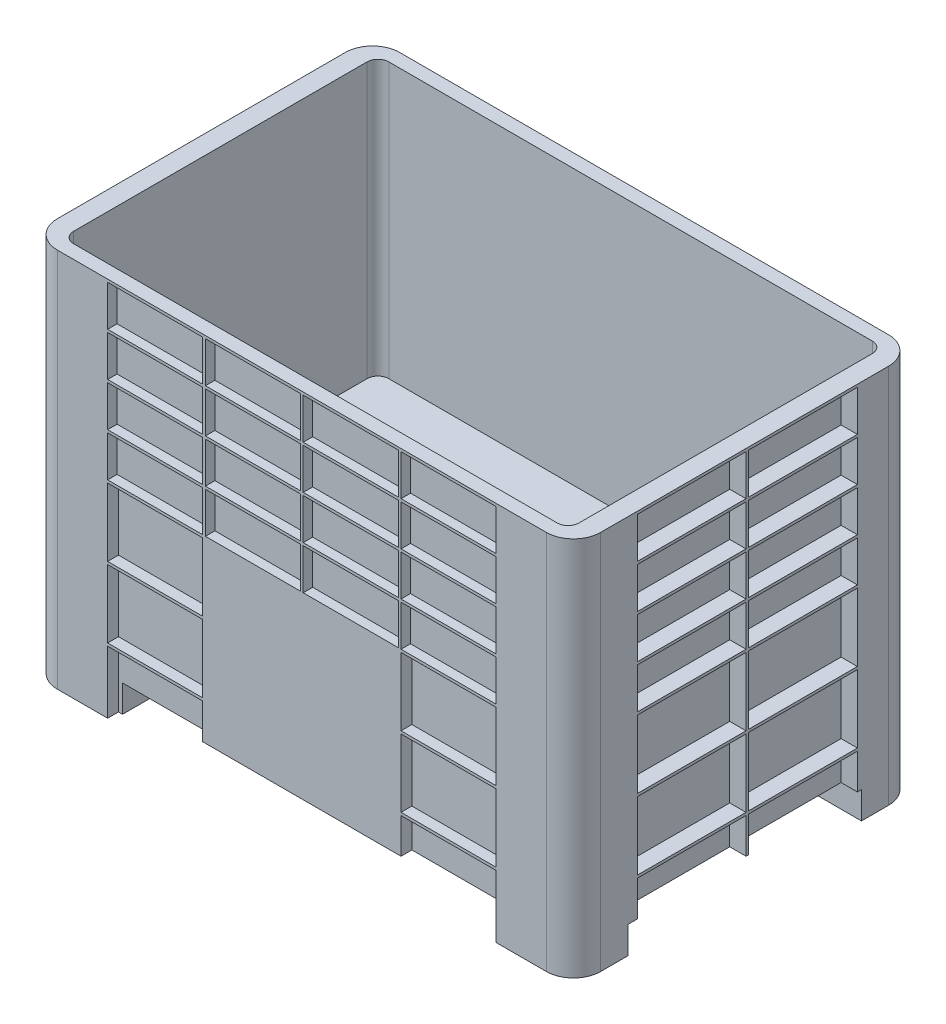
from build123d import *

# Parameters (mm, degrees)
AUFSATZ_LINEAR_AUSTRAGEN1_DEPTH = 650
AUFSATZ_LINEAR_AUSTRAGEN2_DEPTH = 50
SPIEGELN2_COPY_1_DEPTH          = 50
SCHNITT_LINEAR_AUSTRAGEN1_DEPTH = 505
SKIZZE4_W                       = 175
SKIZZE4_H                       = 75
SCHNITT_LINEAR_AUSTRAGEN2_DEPTH = 17.42216744
LINEARES_MUSTER1_COUNT          = 4
LINEARES_MUSTER1_PITCH          = 180
LINEARES_MUSTER1_COUNT_DIR2     = 4
LINEARES_MUSTER1_PITCH_DIR2     = 80
SKIZZE5_W                       = 175
SKIZZE5_H                       = 125
SCHNITT_LINEAR_AUSTRAGEN3_DEPTH = 20
LINEARES_MUSTER2_COUNT          = 2
LINEARES_MUSTER2_PITCH          = 540
LINEARES_MUSTER2_COUNT_DIR2     = 3
LINEARES_MUSTER2_PITCH_DIR2     = 130
SPIEGELN3_COPY_1_SKETCH_W       = 175
SPIEGELN3_COPY_1_SKETCH_H       = 75
SPIEGELN3_COPY_1_DEPTH          = 17.42216744
SPIEGELN3_COPY_2_SKETCH_W       = 175
SPIEGELN3_COPY_2_SKETCH_H       = 75
SPIEGELN3_COPY_2_DEPTH          = 17.42216744
SPIEGELN3_COPY_3_SKETCH_W       = 175
SPIEGELN3_COPY_3_SKETCH_H       = 75
SPIEGELN3_COPY_3_DEPTH          = 17.42216744
SPIEGELN3_COPY_4_SKETCH_W       = 175
SPIEGELN3_COPY_4_SKETCH_H       = 75
SPIEGELN3_COPY_4_DEPTH          = 17.42216744
SPIEGELN3_COPY_5_SKETCH_W       = 175
SPIEGELN3_COPY_5_SKETCH_H       = 75
SPIEGELN3_COPY_5_DEPTH          = 17.42216744
SPIEGELN3_COPY_6_SKETCH_W       = 175
SPIEGELN3_COPY_6_SKETCH_H       = 75
SPIEGELN3_COPY_6_DEPTH          = 17.42216744
SPIEGELN3_COPY_7_SKETCH_W       = 175
SPIEGELN3_COPY_7_SKETCH_H       = 75
SPIEGELN3_COPY_7_DEPTH          = 17.42216744
SPIEGELN3_COPY_8_SKETCH_W       = 175
SPIEGELN3_COPY_8_SKETCH_H       = 75
SPIEGELN3_COPY_8_DEPTH          = 17.42216744
SPIEGELN3_COPY_9_SKETCH_W       = 175
SPIEGELN3_COPY_9_SKETCH_H       = 75
SPIEGELN3_COPY_9_DEPTH          = 17.42216744
SPIEGELN3_COPY_10_SKETCH_W      = 175
SPIEGELN3_COPY_10_SKETCH_H      = 75
SPIEGELN3_COPY_10_DEPTH         = 17.42216744
SPIEGELN3_COPY_11_SKETCH_W      = 175
SPIEGELN3_COPY_11_SKETCH_H      = 75
SPIEGELN3_COPY_11_DEPTH         = 17.42216744
SPIEGELN3_COPY_12_SKETCH_W      = 175
SPIEGELN3_COPY_12_SKETCH_H      = 75
SPIEGELN3_COPY_12_DEPTH         = 17.42216744
SPIEGELN3_COPY_13_SKETCH_W      = 175
SPIEGELN3_COPY_13_SKETCH_H      = 75
SPIEGELN3_COPY_13_DEPTH         = 17.42216744
SPIEGELN3_COPY_14_SKETCH_W      = 175
SPIEGELN3_COPY_14_SKETCH_H      = 75
SPIEGELN3_COPY_14_DEPTH         = 17.42216744
SPIEGELN3_COPY_15_SKETCH_W      = 175
SPIEGELN3_COPY_15_SKETCH_H      = 75
SPIEGELN3_COPY_15_DEPTH         = 17.42216744
SPIEGELN3_COPY_16_SKETCH_W      = 175
SPIEGELN3_COPY_16_SKETCH_H      = 125
SPIEGELN3_COPY_16_DEPTH         = 20
SPIEGELN3_COPY_17_SKETCH_W      = 175
SPIEGELN3_COPY_17_SKETCH_H      = 125
SPIEGELN3_COPY_17_DEPTH         = 20
SPIEGELN3_COPY_18_SKETCH_W      = 175
SPIEGELN3_COPY_18_SKETCH_H      = 125
SPIEGELN3_COPY_18_DEPTH         = 20
SPIEGELN3_COPY_19_SKETCH_W      = 175
SPIEGELN3_COPY_19_SKETCH_H      = 125
SPIEGELN3_COPY_19_DEPTH         = 20
SPIEGELN3_COPY_20_SKETCH_W      = 175
SPIEGELN3_COPY_20_SKETCH_H      = 125
SPIEGELN3_COPY_20_DEPTH         = 20
SKIZZE6_W                       = 200
SKIZZE6_H                       = 75
SCHNITT_LINEAR_AUSTRAGEN4_DEPTH = 30
LINEARES_MUSTER3_COUNT          = 2
LINEARES_MUSTER3_PITCH          = 205
LINEARES_MUSTER3_COUNT_DIR2     = 4
LINEARES_MUSTER3_PITCH_DIR2     = 80
SKIZZE7_W                       = 200
SKIZZE7_H                       = 125
SCHNITT_LINEAR_AUSTRAGEN5_DEPTH = 30
LINEARES_MUSTER4_COUNT          = 2
LINEARES_MUSTER4_PITCH          = 205
LINEARES_MUSTER4_COUNT_DIR2     = 3
LINEARES_MUSTER4_PITCH_DIR2     = 130
SPIEGELN4_COPY_1_SKETCH_W       = 200
SPIEGELN4_COPY_1_SKETCH_H       = 75
SPIEGELN4_COPY_1_DEPTH          = 30
SPIEGELN4_COPY_2_SKETCH_W       = 200
SPIEGELN4_COPY_2_SKETCH_H       = 75
SPIEGELN4_COPY_2_DEPTH          = 30
SPIEGELN4_COPY_3_SKETCH_W       = 200
SPIEGELN4_COPY_3_SKETCH_H       = 75
SPIEGELN4_COPY_3_DEPTH          = 30
SPIEGELN4_COPY_4_SKETCH_W       = 200
SPIEGELN4_COPY_4_SKETCH_H       = 75
SPIEGELN4_COPY_4_DEPTH          = 30
SPIEGELN4_COPY_5_SKETCH_W       = 200
SPIEGELN4_COPY_5_SKETCH_H       = 75
SPIEGELN4_COPY_5_DEPTH          = 30
SPIEGELN4_COPY_6_SKETCH_W       = 200
SPIEGELN4_COPY_6_SKETCH_H       = 75
SPIEGELN4_COPY_6_DEPTH          = 30
SPIEGELN4_COPY_7_SKETCH_W       = 200
SPIEGELN4_COPY_7_SKETCH_H       = 75
SPIEGELN4_COPY_7_DEPTH          = 30
SPIEGELN4_COPY_8_SKETCH_W       = 200
SPIEGELN4_COPY_8_SKETCH_H       = 125
SPIEGELN4_COPY_8_DEPTH          = 30
SPIEGELN4_COPY_9_SKETCH_W       = 200
SPIEGELN4_COPY_9_SKETCH_H       = 125
SPIEGELN4_COPY_9_DEPTH          = 30
SPIEGELN4_COPY_10_SKETCH_W      = 200
SPIEGELN4_COPY_10_SKETCH_H      = 125
SPIEGELN4_COPY_10_DEPTH         = 30
SPIEGELN4_COPY_11_SKETCH_W      = 200
SPIEGELN4_COPY_11_SKETCH_H      = 125
SPIEGELN4_COPY_11_DEPTH         = 30
SPIEGELN4_COPY_12_SKETCH_W      = 200
SPIEGELN4_COPY_12_SKETCH_H      = 125
SPIEGELN4_COPY_12_DEPTH         = 30


with BuildPart() as part:
    # Skizze1 → Aufsatz-Linear austragen1 (new body)
    with BuildSketch(Plane(origin=(0, 100, 0), x_dir=(1, 0, 0), z_dir=(0, 1, 0))):
        with BuildLine():
            Line((-450, -315), (450, -315))
            ThreePointArc((450, -315), (485.355339059, -300.355339059), (500, -265))
            Line((500, -265), (500, 265))
            ThreePointArc((500, 265), (485.355339059, 300.355339059), (450, 315))
            Line((450, 315), (-450, 315))
            ThreePointArc((-450, 315), (-485.355339059, 300.355339059), (-500, 265))
            Line((-500, 265), (-500, -265))
            ThreePointArc((-500, -265), (-485.355339059, -300.355339059), (-450, -315))
        make_face()
    extrude(amount=AUFSATZ_LINEAR_AUSTRAGEN1_DEPTH)

    # Skizze2 → Aufsatz-Linear austragen2 (add)
    with BuildSketch(Plane.XZ.offset(-100)):
        with BuildLine():
            Line((450, 315), (350, 315))
            Line((350, 315), (350, 215))
            Line((350, 215), (500, 215))
            Line((500, 215), (500, 265))
            ThreePointArc((500, 265), (485.355339059, 300.355339059), (450, 315))
        make_face()
    aufsatz_linear_austragen2 = extrude(amount=AUFSATZ_LINEAR_AUSTRAGEN2_DEPTH)

    # Spiegeln1: Aufsatz-Linear austragen2 across plane
    add(aufsatz_linear_austragen2.mirror(Plane.XY))

    # Spiegeln2: Aufsatz-Linear austragen2 across plane
    add(aufsatz_linear_austragen2.mirror(Plane(origin=(0, 0, 0), x_dir=(0, 0, 1), z_dir=(1, 0, 0))))

    # Spiegeln2 copy 1 sketch → Spiegeln2 copy 1 (add)
    with BuildSketch(Plane(origin=(0, 100, 0), x_dir=(-1, 0, 0), z_dir=(0, -1, 0))):
        with BuildLine():
            Line((450, 315), (350, 315))
            Line((350, 315), (350, 215))
            Line((350, 215), (500, 215))
            Line((500, 215), (500, 265))
            ThreePointArc((500, 265), (485.355339059, 300.355339059), (450, 315))
        make_face()
    extrude(amount=SPIEGELN2_COPY_1_DEPTH)

    # Skizze3 → Schnitt-Linear austragen1 (cut)
    with BuildSketch(Plane(origin=(0, 750, 0), x_dir=(1, 0, 0), z_dir=(0, 1, 0))):
        with BuildLine():
            Line((445, -290), (-445, -290))
            ThreePointArc((-445, -290), (-459.142135624, -284.142135624), (-465, -270))
            Line((-465, -270), (-465, 270))
            ThreePointArc((-465, 270), (-459.142135624, 284.142135624), (-445, 290))
            Line((-445, 290), (445, 290))
            ThreePointArc((445, 290), (459.142135624, 284.142135624), (465, 270))
            Line((465, 270), (465, -270))
            ThreePointArc((465, -270), (459.142135624, -284.142135624), (445, -290))
        make_face()
    extrude(amount=-SCHNITT_LINEAR_AUSTRAGEN1_DEPTH, mode=Mode.SUBTRACT)

    # Skizze4 → Schnitt-Linear austragen2 (cut)
    with BuildSketch(Plane.XY.offset(315)):
        with Locations((-270, 707.5)):
            Rectangle(SKIZZE4_W, SKIZZE4_H)
    schnitt_linear_austragen2 = extrude(amount=-SCHNITT_LINEAR_AUSTRAGEN2_DEPTH, mode=Mode.SUBTRACT)

    # Lineares Muster1: Schnitt-Linear austragen2 4 × 4
    with Locations(*[(i * LINEARES_MUSTER1_PITCH, -j * LINEARES_MUSTER1_PITCH_DIR2, 0) for i in range(LINEARES_MUSTER1_COUNT) for j in range(LINEARES_MUSTER1_COUNT_DIR2) if (i, j) != (0, 0)]):
        add(schnitt_linear_austragen2, mode=Mode.SUBTRACT)

    # Skizze5 → Schnitt-Linear austragen3 (cut)
    with BuildSketch(Plane.XY.offset(315)):
        with Locations((-270, 362.5)):
            Rectangle(SKIZZE5_W, SKIZZE5_H)
    schnitt_linear_austragen3 = extrude(amount=-SCHNITT_LINEAR_AUSTRAGEN3_DEPTH, mode=Mode.SUBTRACT)

    # Lineares Muster2: Schnitt-Linear austragen3 2 × 3
    with Locations(*[(i * LINEARES_MUSTER2_PITCH, -j * LINEARES_MUSTER2_PITCH_DIR2, 0) for i in range(LINEARES_MUSTER2_COUNT) for j in range(LINEARES_MUSTER2_COUNT_DIR2) if (i, j) != (0, 0)]):
        add(schnitt_linear_austragen3, mode=Mode.SUBTRACT)

    # Spiegeln3: Schnitt-Linear austragen2, Schnitt-Linear austragen3 across plane
    add(schnitt_linear_austragen2.mirror(Plane.XY), mode=Mode.SUBTRACT)
    add(schnitt_linear_austragen3.mirror(Plane.XY), mode=Mode.SUBTRACT)

    # Spiegeln3 copy 1 sketch → Spiegeln3 copy 1 (cut)
    with BuildSketch(Plane(origin=(0, -80, -315), x_dir=(1, 0, 0), z_dir=(0, 0, -1))):
        with Locations((-270, -707.5)):
            Rectangle(SPIEGELN3_COPY_1_SKETCH_W, SPIEGELN3_COPY_1_SKETCH_H)
    extrude(amount=-SPIEGELN3_COPY_1_DEPTH, mode=Mode.SUBTRACT)

    # Spiegeln3 copy 2 sketch → Spiegeln3 copy 2 (cut)
    with BuildSketch(Plane(origin=(0, -160, -315), x_dir=(1, 0, 0), z_dir=(0, 0, -1))):
        with Locations((-270, -707.5)):
            Rectangle(SPIEGELN3_COPY_2_SKETCH_W, SPIEGELN3_COPY_2_SKETCH_H)
    extrude(amount=-SPIEGELN3_COPY_2_DEPTH, mode=Mode.SUBTRACT)

    # Spiegeln3 copy 3 sketch → Spiegeln3 copy 3 (cut)
    with BuildSketch(Plane(origin=(0, -240, -315), x_dir=(1, 0, 0), z_dir=(0, 0, -1))):
        with Locations((-270, -707.5)):
            Rectangle(SPIEGELN3_COPY_3_SKETCH_W, SPIEGELN3_COPY_3_SKETCH_H)
    extrude(amount=-SPIEGELN3_COPY_3_DEPTH, mode=Mode.SUBTRACT)

    # Spiegeln3 copy 4 sketch → Spiegeln3 copy 4 (cut)
    with BuildSketch(Plane(origin=(180, 0, -315), x_dir=(1, 0, 0), z_dir=(0, 0, -1))):
        with Locations((-270, -707.5)):
            Rectangle(SPIEGELN3_COPY_4_SKETCH_W, SPIEGELN3_COPY_4_SKETCH_H)
    extrude(amount=-SPIEGELN3_COPY_4_DEPTH, mode=Mode.SUBTRACT)

    # Spiegeln3 copy 5 sketch → Spiegeln3 copy 5 (cut)
    with BuildSketch(Plane(origin=(180, -80, -315), x_dir=(1, 0, 0), z_dir=(0, 0, -1))):
        with Locations((-270, -707.5)):
            Rectangle(SPIEGELN3_COPY_5_SKETCH_W, SPIEGELN3_COPY_5_SKETCH_H)
    extrude(amount=-SPIEGELN3_COPY_5_DEPTH, mode=Mode.SUBTRACT)

    # Spiegeln3 copy 6 sketch → Spiegeln3 copy 6 (cut)
    with BuildSketch(Plane(origin=(180, -160, -315), x_dir=(1, 0, 0), z_dir=(0, 0, -1))):
        with Locations((-270, -707.5)):
            Rectangle(SPIEGELN3_COPY_6_SKETCH_W, SPIEGELN3_COPY_6_SKETCH_H)
    extrude(amount=-SPIEGELN3_COPY_6_DEPTH, mode=Mode.SUBTRACT)

    # Spiegeln3 copy 7 sketch → Spiegeln3 copy 7 (cut)
    with BuildSketch(Plane(origin=(180, -240, -315), x_dir=(1, 0, 0), z_dir=(0, 0, -1))):
        with Locations((-270, -707.5)):
            Rectangle(SPIEGELN3_COPY_7_SKETCH_W, SPIEGELN3_COPY_7_SKETCH_H)
    extrude(amount=-SPIEGELN3_COPY_7_DEPTH, mode=Mode.SUBTRACT)

    # Spiegeln3 copy 8 sketch → Spiegeln3 copy 8 (cut)
    with BuildSketch(Plane(origin=(360, 0, -315), x_dir=(1, 0, 0), z_dir=(0, 0, -1))):
        with Locations((-270, -707.5)):
            Rectangle(SPIEGELN3_COPY_8_SKETCH_W, SPIEGELN3_COPY_8_SKETCH_H)
    extrude(amount=-SPIEGELN3_COPY_8_DEPTH, mode=Mode.SUBTRACT)

    # Spiegeln3 copy 9 sketch → Spiegeln3 copy 9 (cut)
    with BuildSketch(Plane(origin=(360, -80, -315), x_dir=(1, 0, 0), z_dir=(0, 0, -1))):
        with Locations((-270, -707.5)):
            Rectangle(SPIEGELN3_COPY_9_SKETCH_W, SPIEGELN3_COPY_9_SKETCH_H)
    extrude(amount=-SPIEGELN3_COPY_9_DEPTH, mode=Mode.SUBTRACT)

    # Spiegeln3 copy 10 sketch → Spiegeln3 copy 10 (cut)
    with BuildSketch(Plane(origin=(360, -160, -315), x_dir=(1, 0, 0), z_dir=(0, 0, -1))):
        with Locations((-270, -707.5)):
            Rectangle(SPIEGELN3_COPY_10_SKETCH_W, SPIEGELN3_COPY_10_SKETCH_H)
    extrude(amount=-SPIEGELN3_COPY_10_DEPTH, mode=Mode.SUBTRACT)

    # Spiegeln3 copy 11 sketch → Spiegeln3 copy 11 (cut)
    with BuildSketch(Plane(origin=(360, -240, -315), x_dir=(1, 0, 0), z_dir=(0, 0, -1))):
        with Locations((-270, -707.5)):
            Rectangle(SPIEGELN3_COPY_11_SKETCH_W, SPIEGELN3_COPY_11_SKETCH_H)
    extrude(amount=-SPIEGELN3_COPY_11_DEPTH, mode=Mode.SUBTRACT)

    # Spiegeln3 copy 12 sketch → Spiegeln3 copy 12 (cut)
    with BuildSketch(Plane(origin=(540, 0, -315), x_dir=(1, 0, 0), z_dir=(0, 0, -1))):
        with Locations((-270, -707.5)):
            Rectangle(SPIEGELN3_COPY_12_SKETCH_W, SPIEGELN3_COPY_12_SKETCH_H)
    extrude(amount=-SPIEGELN3_COPY_12_DEPTH, mode=Mode.SUBTRACT)

    # Spiegeln3 copy 13 sketch → Spiegeln3 copy 13 (cut)
    with BuildSketch(Plane(origin=(540, -80, -315), x_dir=(1, 0, 0), z_dir=(0, 0, -1))):
        with Locations((-270, -707.5)):
            Rectangle(SPIEGELN3_COPY_13_SKETCH_W, SPIEGELN3_COPY_13_SKETCH_H)
    extrude(amount=-SPIEGELN3_COPY_13_DEPTH, mode=Mode.SUBTRACT)

    # Spiegeln3 copy 14 sketch → Spiegeln3 copy 14 (cut)
    with BuildSketch(Plane(origin=(540, -160, -315), x_dir=(1, 0, 0), z_dir=(0, 0, -1))):
        with Locations((-270, -707.5)):
            Rectangle(SPIEGELN3_COPY_14_SKETCH_W, SPIEGELN3_COPY_14_SKETCH_H)
    extrude(amount=-SPIEGELN3_COPY_14_DEPTH, mode=Mode.SUBTRACT)

    # Spiegeln3 copy 15 sketch → Spiegeln3 copy 15 (cut)
    with BuildSketch(Plane(origin=(540, -240, -315), x_dir=(1, 0, 0), z_dir=(0, 0, -1))):
        with Locations((-270, -707.5)):
            Rectangle(SPIEGELN3_COPY_15_SKETCH_W, SPIEGELN3_COPY_15_SKETCH_H)
    extrude(amount=-SPIEGELN3_COPY_15_DEPTH, mode=Mode.SUBTRACT)

    # Spiegeln3 copy 16 sketch → Spiegeln3 copy 16 (cut)
    with BuildSketch(Plane(origin=(0, -130, -315), x_dir=(1, 0, 0), z_dir=(0, 0, -1))):
        with Locations((-270, -362.5)):
            Rectangle(SPIEGELN3_COPY_16_SKETCH_W, SPIEGELN3_COPY_16_SKETCH_H)
    extrude(amount=-SPIEGELN3_COPY_16_DEPTH, mode=Mode.SUBTRACT)

    # Spiegeln3 copy 17 sketch → Spiegeln3 copy 17 (cut)
    with BuildSketch(Plane(origin=(0, -260, -315), x_dir=(1, 0, 0), z_dir=(0, 0, -1))):
        with Locations((-270, -362.5)):
            Rectangle(SPIEGELN3_COPY_17_SKETCH_W, SPIEGELN3_COPY_17_SKETCH_H)
    extrude(amount=-SPIEGELN3_COPY_17_DEPTH, mode=Mode.SUBTRACT)

    # Spiegeln3 copy 18 sketch → Spiegeln3 copy 18 (cut)
    with BuildSketch(Plane(origin=(540, 0, -315), x_dir=(1, 0, 0), z_dir=(0, 0, -1))):
        with Locations((-270, -362.5)):
            Rectangle(SPIEGELN3_COPY_18_SKETCH_W, SPIEGELN3_COPY_18_SKETCH_H)
    extrude(amount=-SPIEGELN3_COPY_18_DEPTH, mode=Mode.SUBTRACT)

    # Spiegeln3 copy 19 sketch → Spiegeln3 copy 19 (cut)
    with BuildSketch(Plane(origin=(540, -130, -315), x_dir=(1, 0, 0), z_dir=(0, 0, -1))):
        with Locations((-270, -362.5)):
            Rectangle(SPIEGELN3_COPY_19_SKETCH_W, SPIEGELN3_COPY_19_SKETCH_H)
    extrude(amount=-SPIEGELN3_COPY_19_DEPTH, mode=Mode.SUBTRACT)

    # Spiegeln3 copy 20 sketch → Spiegeln3 copy 20 (cut)
    with BuildSketch(Plane(origin=(540, -260, -315), x_dir=(1, 0, 0), z_dir=(0, 0, -1))):
        with Locations((-270, -362.5)):
            Rectangle(SPIEGELN3_COPY_20_SKETCH_W, SPIEGELN3_COPY_20_SKETCH_H)
    extrude(amount=-SPIEGELN3_COPY_20_DEPTH, mode=Mode.SUBTRACT)

    # Skizze6 → Schnitt-Linear austragen4 (cut)
    with BuildSketch(Plane.ZY.offset(500)):
        with Locations((-107.5, 707.5)):
            Rectangle(SKIZZE6_W, SKIZZE6_H)
    schnitt_linear_austragen4 = extrude(amount=-SCHNITT_LINEAR_AUSTRAGEN4_DEPTH, mode=Mode.SUBTRACT)

    # Lineares Muster3: Schnitt-Linear austragen4 2 × 4
    with Locations(*[(0, -j * LINEARES_MUSTER3_PITCH_DIR2, i * LINEARES_MUSTER3_PITCH) for i in range(LINEARES_MUSTER3_COUNT) for j in range(LINEARES_MUSTER3_COUNT_DIR2) if (i, j) != (0, 0)]):
        add(schnitt_linear_austragen4, mode=Mode.SUBTRACT)

    # Skizze7 → Schnitt-Linear austragen5 (cut)
    with BuildSketch(Plane.ZY.offset(500)):
        with Locations((-107.5, 362.5)):
            Rectangle(SKIZZE7_W, SKIZZE7_H)
    schnitt_linear_austragen5 = extrude(amount=-SCHNITT_LINEAR_AUSTRAGEN5_DEPTH, mode=Mode.SUBTRACT)

    # Lineares Muster4: Schnitt-Linear austragen5 2 × 3
    with Locations(*[(0, -j * LINEARES_MUSTER4_PITCH_DIR2, i * LINEARES_MUSTER4_PITCH) for i in range(LINEARES_MUSTER4_COUNT) for j in range(LINEARES_MUSTER4_COUNT_DIR2) if (i, j) != (0, 0)]):
        add(schnitt_linear_austragen5, mode=Mode.SUBTRACT)

    # Spiegeln4: Schnitt-Linear austragen4, Schnitt-Linear austragen5 across plane
    add(schnitt_linear_austragen4.mirror(Plane(origin=(0, 0, 0), x_dir=(0, 0, 1), z_dir=(1, 0, 0))), mode=Mode.SUBTRACT)
    add(schnitt_linear_austragen5.mirror(Plane(origin=(0, 0, 0), x_dir=(0, 0, 1), z_dir=(1, 0, 0))), mode=Mode.SUBTRACT)

    # Spiegeln4 copy 1 sketch → Spiegeln4 copy 1 (cut)
    with BuildSketch(Plane(origin=(500, -80, 0), x_dir=(0, 0, 1), z_dir=(1, 0, 0))):
        with Locations((-107.5, -707.5)):
            Rectangle(SPIEGELN4_COPY_1_SKETCH_W, SPIEGELN4_COPY_1_SKETCH_H)
    extrude(amount=-SPIEGELN4_COPY_1_DEPTH, mode=Mode.SUBTRACT)

    # Spiegeln4 copy 2 sketch → Spiegeln4 copy 2 (cut)
    with BuildSketch(Plane(origin=(500, -160, 0), x_dir=(0, 0, 1), z_dir=(1, 0, 0))):
        with Locations((-107.5, -707.5)):
            Rectangle(SPIEGELN4_COPY_2_SKETCH_W, SPIEGELN4_COPY_2_SKETCH_H)
    extrude(amount=-SPIEGELN4_COPY_2_DEPTH, mode=Mode.SUBTRACT)

    # Spiegeln4 copy 3 sketch → Spiegeln4 copy 3 (cut)
    with BuildSketch(Plane(origin=(500, -240, 0), x_dir=(0, 0, 1), z_dir=(1, 0, 0))):
        with Locations((-107.5, -707.5)):
            Rectangle(SPIEGELN4_COPY_3_SKETCH_W, SPIEGELN4_COPY_3_SKETCH_H)
    extrude(amount=-SPIEGELN4_COPY_3_DEPTH, mode=Mode.SUBTRACT)

    # Spiegeln4 copy 4 sketch → Spiegeln4 copy 4 (cut)
    with BuildSketch(Plane(origin=(500, 0, 205), x_dir=(0, 0, 1), z_dir=(1, 0, 0))):
        with Locations((-107.5, -707.5)):
            Rectangle(SPIEGELN4_COPY_4_SKETCH_W, SPIEGELN4_COPY_4_SKETCH_H)
    extrude(amount=-SPIEGELN4_COPY_4_DEPTH, mode=Mode.SUBTRACT)

    # Spiegeln4 copy 5 sketch → Spiegeln4 copy 5 (cut)
    with BuildSketch(Plane(origin=(500, -80, 205), x_dir=(0, 0, 1), z_dir=(1, 0, 0))):
        with Locations((-107.5, -707.5)):
            Rectangle(SPIEGELN4_COPY_5_SKETCH_W, SPIEGELN4_COPY_5_SKETCH_H)
    extrude(amount=-SPIEGELN4_COPY_5_DEPTH, mode=Mode.SUBTRACT)

    # Spiegeln4 copy 6 sketch → Spiegeln4 copy 6 (cut)
    with BuildSketch(Plane(origin=(500, -160, 205), x_dir=(0, 0, 1), z_dir=(1, 0, 0))):
        with Locations((-107.5, -707.5)):
            Rectangle(SPIEGELN4_COPY_6_SKETCH_W, SPIEGELN4_COPY_6_SKETCH_H)
    extrude(amount=-SPIEGELN4_COPY_6_DEPTH, mode=Mode.SUBTRACT)

    # Spiegeln4 copy 7 sketch → Spiegeln4 copy 7 (cut)
    with BuildSketch(Plane(origin=(500, -240, 205), x_dir=(0, 0, 1), z_dir=(1, 0, 0))):
        with Locations((-107.5, -707.5)):
            Rectangle(SPIEGELN4_COPY_7_SKETCH_W, SPIEGELN4_COPY_7_SKETCH_H)
    extrude(amount=-SPIEGELN4_COPY_7_DEPTH, mode=Mode.SUBTRACT)

    # Spiegeln4 copy 8 sketch → Spiegeln4 copy 8 (cut)
    with BuildSketch(Plane(origin=(500, -130, 0), x_dir=(0, 0, 1), z_dir=(1, 0, 0))):
        with Locations((-107.5, -362.5)):
            Rectangle(SPIEGELN4_COPY_8_SKETCH_W, SPIEGELN4_COPY_8_SKETCH_H)
    extrude(amount=-SPIEGELN4_COPY_8_DEPTH, mode=Mode.SUBTRACT)

    # Spiegeln4 copy 9 sketch → Spiegeln4 copy 9 (cut)
    with BuildSketch(Plane(origin=(500, -260, 0), x_dir=(0, 0, 1), z_dir=(1, 0, 0))):
        with Locations((-107.5, -362.5)):
            Rectangle(SPIEGELN4_COPY_9_SKETCH_W, SPIEGELN4_COPY_9_SKETCH_H)
    extrude(amount=-SPIEGELN4_COPY_9_DEPTH, mode=Mode.SUBTRACT)

    # Spiegeln4 copy 10 sketch → Spiegeln4 copy 10 (cut)
    with BuildSketch(Plane(origin=(500, 0, 205), x_dir=(0, 0, 1), z_dir=(1, 0, 0))):
        with Locations((-107.5, -362.5)):
            Rectangle(SPIEGELN4_COPY_10_SKETCH_W, SPIEGELN4_COPY_10_SKETCH_H)
    extrude(amount=-SPIEGELN4_COPY_10_DEPTH, mode=Mode.SUBTRACT)

    # Spiegeln4 copy 11 sketch → Spiegeln4 copy 11 (cut)
    with BuildSketch(Plane(origin=(500, -130, 205), x_dir=(0, 0, 1), z_dir=(1, 0, 0))):
        with Locations((-107.5, -362.5)):
            Rectangle(SPIEGELN4_COPY_11_SKETCH_W, SPIEGELN4_COPY_11_SKETCH_H)
    extrude(amount=-SPIEGELN4_COPY_11_DEPTH, mode=Mode.SUBTRACT)

    # Spiegeln4 copy 12 sketch → Spiegeln4 copy 12 (cut)
    with BuildSketch(Plane(origin=(500, -260, 205), x_dir=(0, 0, 1), z_dir=(1, 0, 0))):
        with Locations((-107.5, -362.5)):
            Rectangle(SPIEGELN4_COPY_12_SKETCH_W, SPIEGELN4_COPY_12_SKETCH_H)
    extrude(amount=-SPIEGELN4_COPY_12_DEPTH, mode=Mode.SUBTRACT)


solid = part.part
